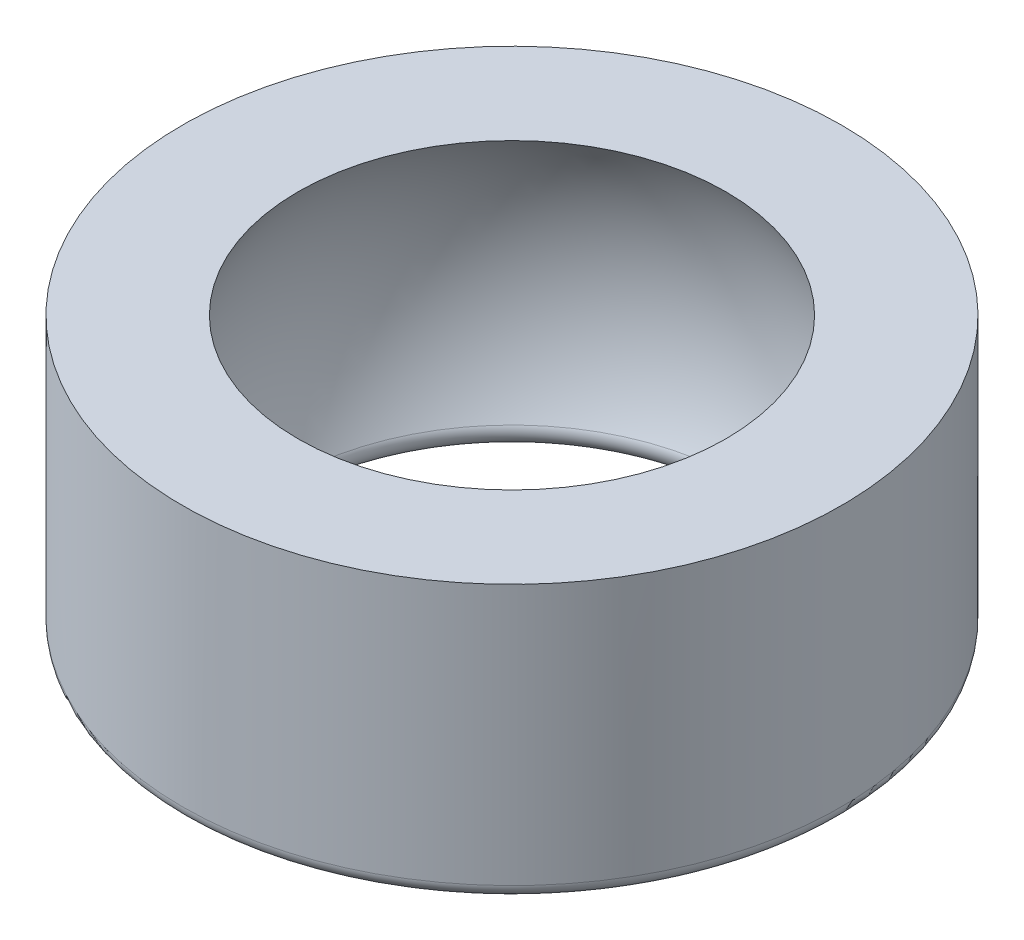
from build123d import *

# Parameters (mm, degrees)
FILLET1_R = 0.3
FILLET2_R = 0.3


with BuildPart() as part:
    # Sketch1 → Revolve1 (revolve)
    with BuildSketch(Plane.XY):
        with BuildLine():
            Line((-4.675256677, 3), (-7.2, 3))
            Line((-7.2, 3), (-7.2, -3))
            Line((-7.2, -3), (-4.675256677, -3))
            ThreePointArc((-4.675256677, -3), (-5.555, 0), (-4.675256677, 3))
        make_face()
    revolve(axis=Axis((0, -3.809768202, 0), (0, 1, 0)))

    # Fillet1
    fillet1_edges = [part.edges().sort_by_distance(p)[0] for p in [
        (4.675256677, -3, 0),
    ]]
    fillet(fillet1_edges, radius=FILLET1_R)

    # Fillet2
    fillet2_edges = [part.edges().sort_by_distance(p)[0] for p in [
        (7.2, -3, 0),
    ]]
    fillet(fillet2_edges, radius=FILLET2_R)


solid = part.part
